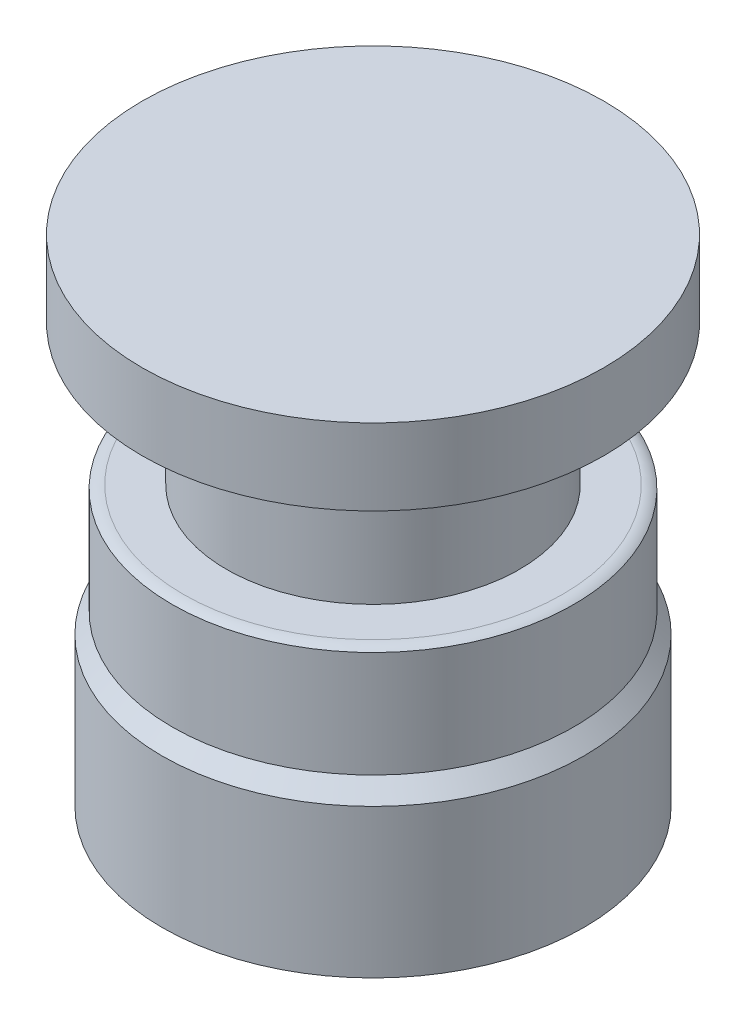
from build123d import *


with BuildPart() as part:
    # Sketch1 → Revolve1 (revolve)
    with BuildSketch(Plane.XY):
        with BuildLine():
            Line((0, 0), (-10.5, 0))
            Line((-10.5, 0), (-10.5, 7.4))
            Line((-10.5, 7.4), (-9.5, 8.4))
            Line((-9.5, 8.4), (-10, 8.4))
            Line((-10, 8.4), (-10, 13.685164654))
            ThreePointArc((-10, 13.685164654), (-9.737084783, 13.807905177), (-9.45, 13.85))
            Line((-9.45, 13.85), (-7.3, 13.85))
            Line((-7.3, 13.85), (-7.3, 20.85))
            Line((-7.3, 20.85), (-11.5, 20.85))
            Line((-11.5, 20.85), (-11.5, 24.65))
            Line((-11.5, 24.65), (0, 24.65))
            Line((0, 24.65), (0, 0))
        make_face()
    revolve(axis=Axis((0, 0, 0), (0, 1, 0)))


solid = part.part
